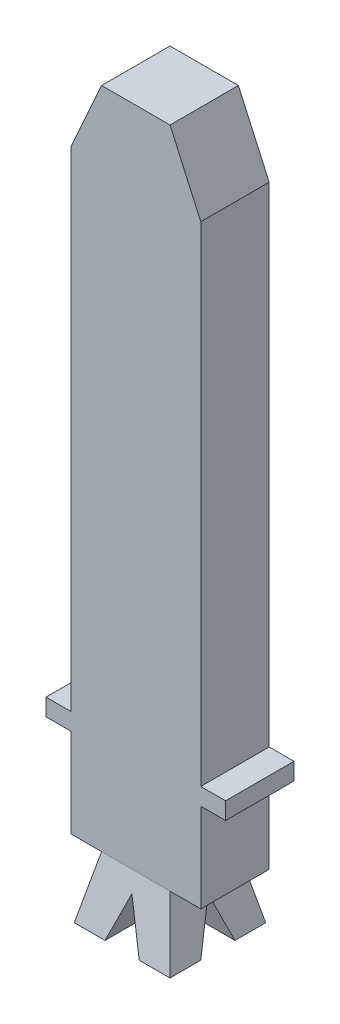
from build123d import *

# Parameters (mm, degrees)
BOSS_EXTRUDE1_DEPTH     = 2
SKETCH2_W               = 2
SKETCH2_H               = 2
SKETCH3_W               = 2.8
SKETCH3_H               = 2.8
CUT_EXTRUDE1_DEPTH      = 1.6000001
CUT_EXTRUDE1_DEPTH_BACK = 3.2000001
CUT_EXTRUDE2_DEPTH      = 5.425
CUT_EXTRUDE2_DEPTH_BACK = 1.825


with BuildPart() as part:
    # Sketch1 → Boss-Extrude1 (new body)
    with BuildSketch(Plane.XY):
        Polygon((1.9, 0), (2.625, 0), (2.625, -0.5), (1.9, -0.5), (1.9, -3.1), (-1.9, -3.1), (-1.9, -0.5), (-2.625, -0.5), (-2.625, 0), (-1.9, 0), (-1.9, 14.3), (-1, 16.3), (1, 16.3), (1.9, 14.3), align=None)
    extrude(amount=BOSS_EXTRUDE1_DEPTH)


with BuildPart() as body_2:
    # Sketch2 → Loft1 section 0
    with BuildSketch(Plane.XZ.offset(3.1)):
        with Locations((0, 1)):
            Rectangle(SKETCH2_W, SKETCH2_H)
    # Sketch3 → Loft1 section 1
    with BuildSketch(Plane(origin=(0, -4.9, 0), x_dir=(-1, 0, 0), z_dir=(0, -1, 0))):
        with Locations((0, -1)):
            Rectangle(SKETCH3_W, SKETCH3_H)
    loft()

    # Sketch4 → Cut-Extrude1 (cut, two sides)
    with BuildSketch(Plane.XY.offset(1.8)) as cut_extrude1_sk:
        Polygon((0, -3.611513086), (-0.5, -4.9), (0.5, -4.9), align=None)
    extrude(amount=CUT_EXTRUDE1_DEPTH, mode=Mode.SUBTRACT)
    extrude(cut_extrude1_sk.sketch, amount=-CUT_EXTRUDE1_DEPTH_BACK, mode=Mode.SUBTRACT)

    # Sketch5 → Cut-Extrude2 (cut, two sides)
    with BuildSketch(Plane(origin=(1.8, 0, -1.8), x_dir=(0, 0, 1), z_dir=(-1, 0, 0))) as cut_extrude2_sk:
        Polygon((2.8, -3.611513086), (2.3, -4.9), (3.3, -4.9), align=None)
    extrude(amount=CUT_EXTRUDE2_DEPTH, mode=Mode.SUBTRACT)
    extrude(cut_extrude2_sk.sketch, amount=-CUT_EXTRUDE2_DEPTH_BACK, mode=Mode.SUBTRACT)


solid = Compound([part.part, body_2.part])
